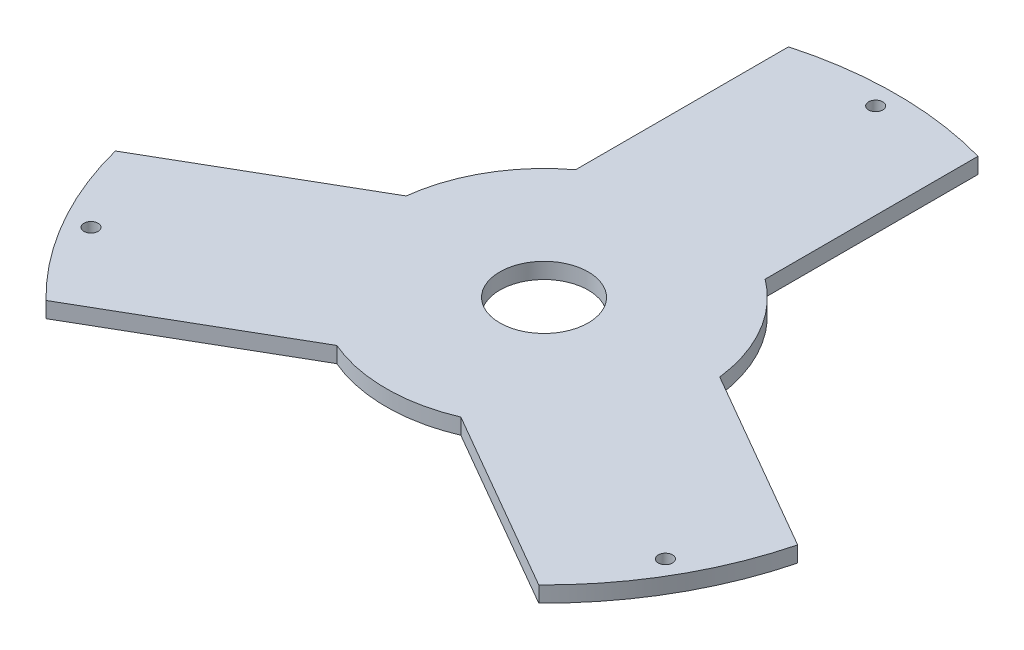
from build123d import *

# Parameters (mm, degrees)
SKETCH2_R            = 111.5
SKETCH2_R_2          = 14
BOSS_EXTRUDE1_DEPTH  = 5
M4_CLEARANCE_HOLE2_D = 4.5
CUT_EXTRUDE1_DEPTH   = 6


with BuildPart() as part:
    # Sketch2 → Boss-Extrude1 (new body)
    with BuildSketch(Plane(origin=(0, 0, 0), x_dir=(1, 0, 0), z_dir=(0, 1, 0))):
        Circle(SKETCH2_R)
        Circle(SKETCH2_R_2, mode=Mode.SUBTRACT)
    extrude(amount=BOSS_EXTRUDE1_DEPTH)

    # M4 Clearance Hole2 (through all)
    with Locations(Plane(origin=(0, 5, 0), x_dir=(1, 0, 0), z_dir=(0, 1, 0))):
        with Locations((-90.932667397, -52.5), (90.932667397, -52.5), (0, 105)):
            Hole(M4_CLEARANCE_HOLE2_D / 2)

    # Sketch8 → Cut-Extrude1 (cut, through all)
    with BuildSketch(Plane(origin=(0, 5, 0), x_dir=(1, 0, 0), z_dir=(0, 1, 0))):
        with BuildLine():
            Line((-30, 40), (-30, 107.388314076))
            ThreePointArc((-30, 107.388314076), (-96.561832522, 55.75), (-108.001008059, -27.713394924))
            Line((-108.001008059, -27.713394924), (-49.641016151, 5.980762114))
            ThreePointArc((-49.641016151, 5.980762114), (-43.301270189, 25), (-30, 40))
        make_face()
        with BuildLine():
            Line((30, 40), (30, 107.388314076))
            ThreePointArc((30, 107.388314076), (96.561832522, 55.75), (108.001008059, -27.713394924))
            Line((108.001008059, -27.713394924), (49.641016151, 5.980762114))
            ThreePointArc((49.641016151, 5.980762114), (43.301270189, 25), (30, 40))
        make_face()
        with BuildLine():
            Line((19.641016151, -45.980762114), (78.001008059, -79.674919151))
            ThreePointArc((78.001008059, -79.674919151), (0, -111.5), (-78.001008059, -79.674919151))
            Line((-78.001008059, -79.674919151), (-19.641016151, -45.980762114))
            ThreePointArc((-19.641016151, -45.980762114), (0, -50), (19.641016151, -45.980762114))
        make_face()
    extrude(amount=-CUT_EXTRUDE1_DEPTH, mode=Mode.SUBTRACT)


solid = part.part
